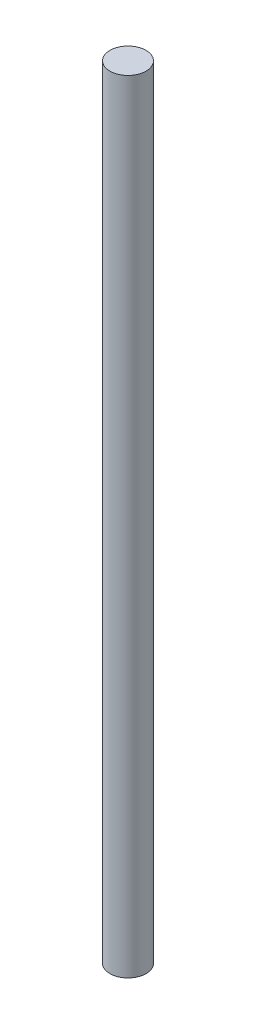
from build123d import *

# Parameters (mm, degrees)
SKETCH1_R           = 1.5
BOSS_EXTRUDE1_DEPTH = 65


with BuildPart() as part:
    # Sketch1 → Boss-Extrude1 (new body)
    with BuildSketch(Plane(origin=(0, 0, 0), x_dir=(1, 0, 0), z_dir=(0, 1, 0))):
        Circle(SKETCH1_R)
    extrude(amount=BOSS_EXTRUDE1_DEPTH)


solid = part.part
